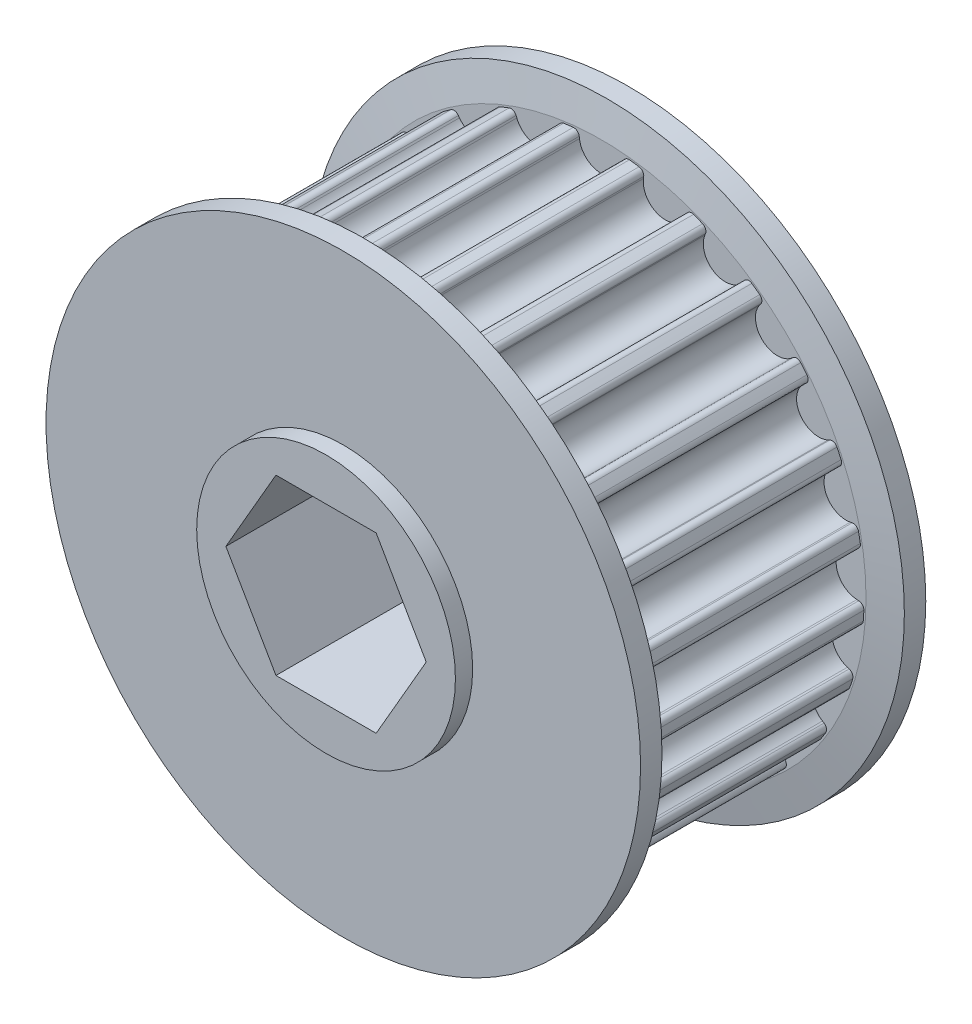
from build123d import *

# Parameters (mm, degrees)
SKETCH2_R                                 = 19.346823944
PULLEY_DEPTH                              = 8.500000018
CUT_TOOTH_DEPTH                           = 8.500000018
BLEND_TOOTH_R                             = 0.4
TOOTH_PATTERN_COUNT                       = 25
BLEND_TOOTH_OF_TOOTH_PATTERN_R            = 0.4
SIDEWALL_START                            = 8.500000018
SKETCH3_R                                 = 21.886823944
SIDEWALL_DEPTH                            = 2.000000064
SIDEWALL_CHAMFER_SIZE                     = 2.400000026
SIDEWALL_CHAMFER_SIZE2                    = 0.423184758
SIDEWALL_CHAMFER_PART_2_SIZE              = 2.400000026
SIDEWALL_CHAMFER_PART_2_SIZE2             = 0.423184758
SKETCH5_R                                 = 9.525
BEARING_SPACER_MANUAL_SUPPRESS_DEPTH      = 11.770000082
BEARING_SPACER_MANUAL_SUPPRESS_DEPTH_BACK = 11.770000082
HEX_SHAFT_DEPTH                           = 63.5


with BuildPart() as part:
    # Sketch2 → pulley (new body, symmetric)
    with BuildSketch(Plane.XY):
        Circle(SKETCH2_R)
    extrude(amount=PULLEY_DEPTH, both=True)

    # tooth → cut tooth (cut, symmetric)
    with BuildSketch(Plane.XY):
        with BuildLine():
            Line((-2.132711961, 22.982416391), (-1.612887548, 18.748786293))
            ThreePointArc((-1.612887548, 18.748786293), (0, 17.32182393), (1.612887548, 18.748786293))
            Line((1.612887548, 18.748786293), (2.132711961, 22.982416391))
            Line((2.132711961, 22.982416391), (-2.132711961, 22.982416391))
        make_face()
    cut_tooth = extrude(amount=CUT_TOOTH_DEPTH, both=True, mode=Mode.SUBTRACT)

    # blend tooth
    blend_tooth_edges = [part.edges().sort_by_distance(p)[0] for p in [
        (1.677372315, 19.273972575, 0),
        (-1.677372315, 19.273972575, 0),
    ]]
    fillet(blend_tooth_edges, radius=BLEND_TOOTH_R)

    # tooth pattern: cut tooth ×25 about axis
    tooth_pattern_axis = Axis((0, 0, 0), (0, 0, 1))
    for i in range(1, TOOTH_PATTERN_COUNT):
        add(cut_tooth.rotate(tooth_pattern_axis, i * 360 / TOOTH_PATTERN_COUNT), mode=Mode.SUBTRACT)

    # blend tooth of tooth pattern
    blend_tooth_of_tooth_pattern_edges = [part.edges().sort_by_distance(p)[0] for p in [
        (-3.168567486, 19.085590816, 0),
        (-6.417916644, 18.251299753, 0),
        (-7.815414538, 17.697991194, 0),
        (-10.755199667, 16.081830643, 0),
        (-11.971190352, 15.198361697, 0),
        (-14.41669394, 12.901880969, 0),
        (-15.374772249, 11.743763239, 0),
        (-17.172334312, 8.911258664, 0),
        (-17.812300661, 7.551260945, 0),
        (-18.848973764, 4.360709204, 0),
        (-19.130616714, 2.884285155, 0),
        (-19.341262872, -0.463839653, 0),
        (-19.246885761, -1.963920879, 0),
        (-18.618269302, -5.259243758, 0),
        (-18.153802191, -6.688726541, 0),
        (-16.725421399, -9.724190237, 0),
        (-15.920048464, -10.993254915, 0),
        (-13.781653757, -13.578130079, 0),
        (-12.685979542, -14.607036653, 0),
        (-9.971934124, -16.578906072, 0),
        (-8.654803869, -17.303004557, 0),
        (-5.535641196, -18.537968423, 0),
        (-4.07981504, -18.911761049, 0),
        (-0.751523573, -19.332222041, 0),
        (0.751523573, -19.332222041, 0),
        (4.07981504, -18.911761049, 0),
        (5.535641196, -18.537968423, 0),
        (8.654803869, -17.303004557, 0),
        (9.971934124, -16.578906072, 0),
        (12.685979542, -14.607036653, 0),
        (13.781653757, -13.578130079, 0),
        (15.920048464, -10.993254915, 0),
        (16.725421399, -9.724190237, 0),
        (18.153802191, -6.688726541, 0),
        (18.618269302, -5.259243758, 0),
        (19.246885761, -1.963920879, 0),
        (19.341262872, -0.463839653, 0),
        (19.130616714, 2.884285155, 0),
        (18.848973764, 4.360709204, 0),
        (17.812300661, 7.551260945, 0),
        (17.172334312, 8.911258664, 0),
        (15.374772249, 11.743763239, 0),
        (14.41669394, 12.901880969, 0),
        (11.971190352, 15.198361697, 0),
        (10.755199667, 16.081830643, 0),
        (7.815414538, 17.697991194, 0),
        (6.417916644, 18.251299753, 0),
        (3.168567486, 19.085590816, 0),
    ]]
    fillet(blend_tooth_of_tooth_pattern_edges, radius=BLEND_TOOTH_OF_TOOTH_PATTERN_R)

    # Sketch3 → sidewall (add)
    with BuildSketch(Plane.XY.offset(SIDEWALL_START)):
        Circle(SKETCH3_R)
    sidewall = extrude(amount=SIDEWALL_DEPTH)

    # mirror sidewall: sidewall across plane
    add(sidewall.mirror(Plane.XY))

    # sidewall chamfer
    sidewall_chamfer_edges = [part.edges().sort_by_distance(p)[0] for p in [
        (-21.886823944, 0, 8.500000018),
    ]]
    sidewall_chamfer_side = [part.faces().sort_by_distance(p)[0] for p in [
        (-21.267771079, 0, 8.500000018),
    ]]
    chamfer(sidewall_chamfer_edges, length=SIDEWALL_CHAMFER_SIZE, length2=SIDEWALL_CHAMFER_SIZE2, reference=sidewall_chamfer_side[0])

    # sidewall chamfer part 2
    sidewall_chamfer_part_2_edges = [part.edges().sort_by_distance(p)[0] for p in [
        (-21.886823944, 0, -8.500000018),
    ]]
    sidewall_chamfer_part_2_side = [part.faces().sort_by_distance(p)[0] for p in [
        (-21.267771079, 0, -8.500000018),
    ]]
    chamfer(sidewall_chamfer_part_2_edges, length=SIDEWALL_CHAMFER_PART_2_SIZE, length2=SIDEWALL_CHAMFER_PART_2_SIZE2, reference=sidewall_chamfer_part_2_side[0])

    # Sketch5 → bearing spacer (Manual Suppress) (add, two sides)
    with BuildSketch(Plane.XY) as bearing_spacer_manual_suppress_sk:
        Circle(SKETCH5_R)
    extrude(amount=BEARING_SPACER_MANUAL_SUPPRESS_DEPTH)
    extrude(bearing_spacer_manual_suppress_sk.sketch, amount=-BEARING_SPACER_MANUAL_SUPPRESS_DEPTH_BACK)

    # Sketch4 → hex shaft (cut, symmetric)
    with BuildSketch(Plane.XY):
        Polygon((3.688171255, 6.3881), (-3.688171255, 6.3881), (-7.376342509, 0), (-3.688171255, -6.3881), (3.688171255, -6.3881), (7.376342509, 0), align=None)
    extrude(amount=HEX_SHAFT_DEPTH, both=True, mode=Mode.SUBTRACT)


solid = part.part
